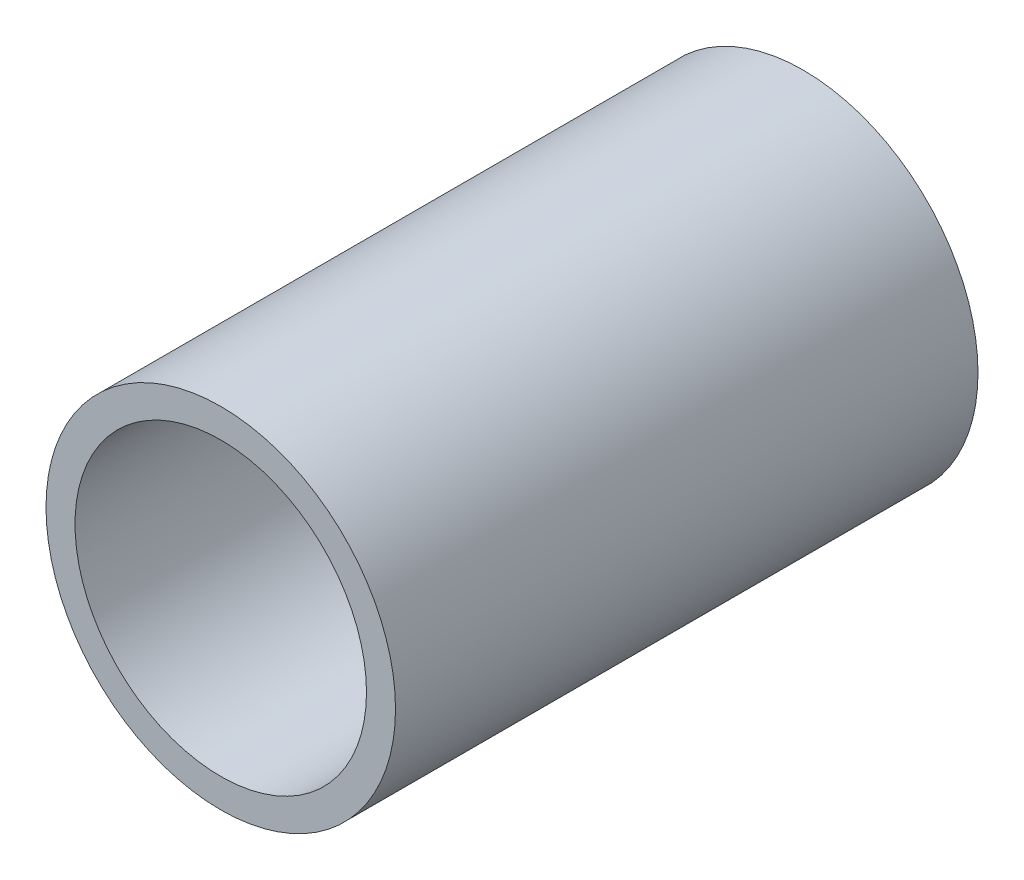
from build123d import *

# Parameters (mm, degrees)
SKETCH1_R      = 19.05
SKETCH1_R_2    = 15.8877
EXTRUDE1_DEPTH = 31.75


with BuildPart() as part:
    # Sketch1 → Extrude1 (new body, symmetric)
    with BuildSketch(Plane.XY):
        Circle(SKETCH1_R)
        Circle(SKETCH1_R_2, mode=Mode.SUBTRACT)
    extrude(amount=EXTRUDE1_DEPTH, both=True)


solid = part.part
